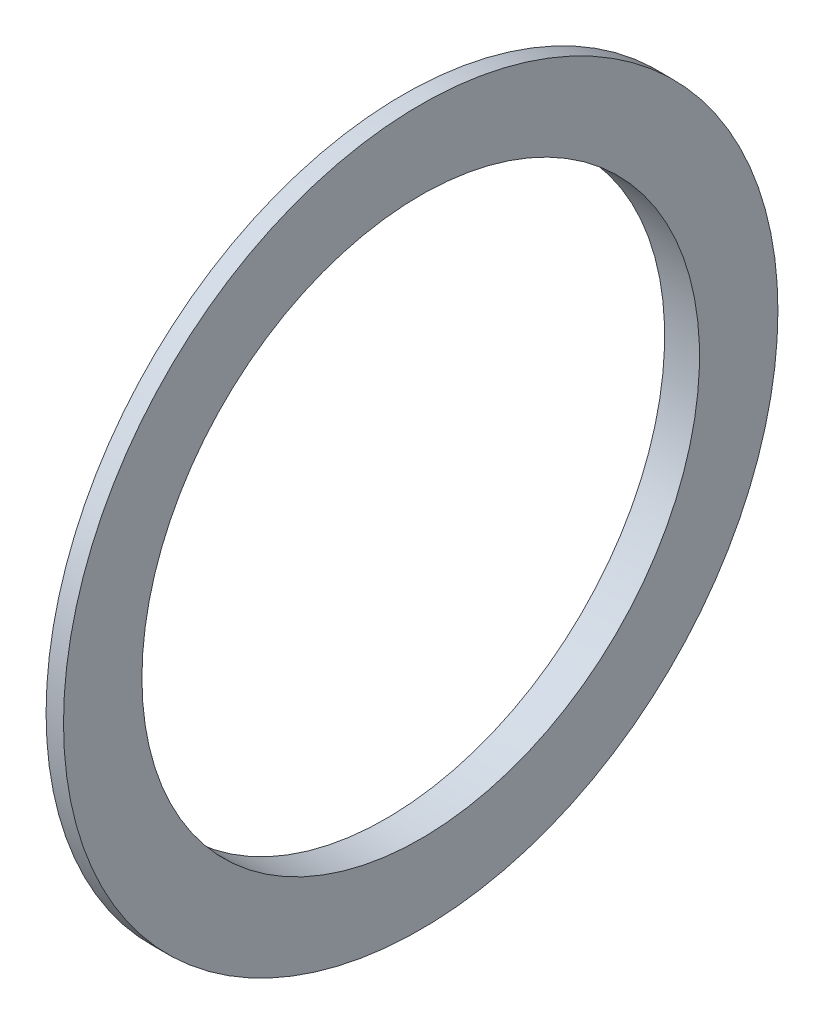
from build123d import *


with BuildPart() as part:
    # Szkic1 → Obrót1 (revolve)
    with BuildSketch(Plane.XY):
        Polygon((153.342300415, 16), (153.342300415, 17.5), (154.342300415, 20.5), (155.342300415, 20.5), (155.342300415, 16), align=None)
    revolve(axis=Axis((0, 0, 0), (1, 0, 0)))


solid = part.part
